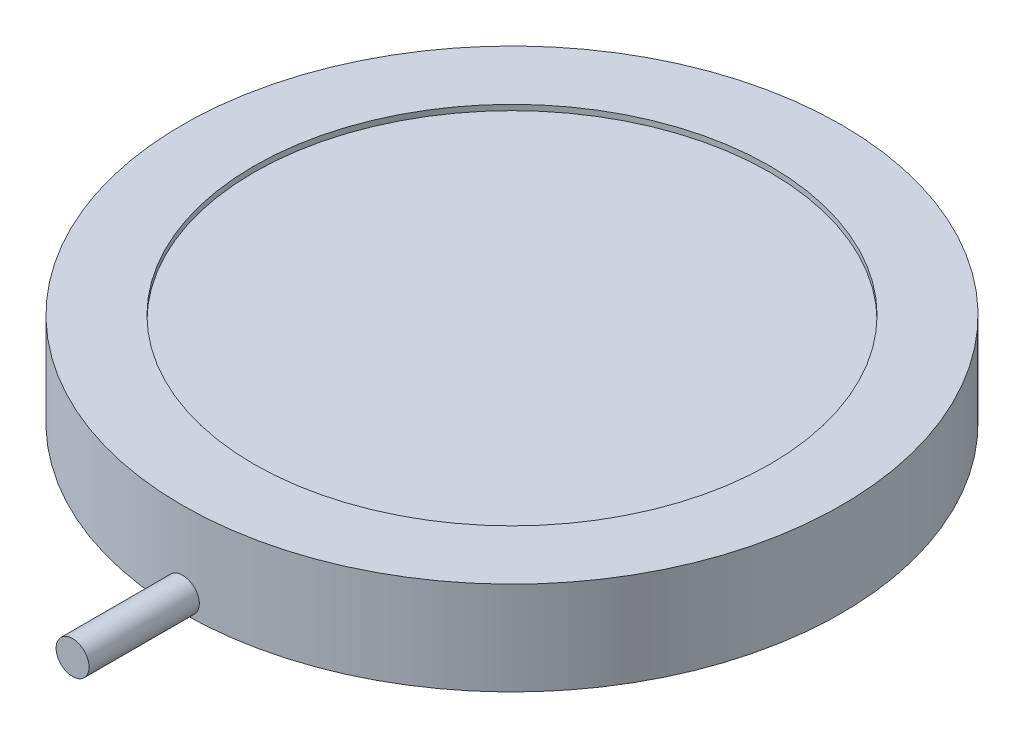
from build123d import *

# Parameters (mm, degrees)
SKETCH_1_R          = 30
EXTRUDE_1_DEPTH     = 8.5
SKETCH_2_R          = 23.5
CUT_EXTRUDE_1_DEPTH = 0.5
SKETCH_3_R          = 1.5
EXTRUDE_2_DEPTH     = 15
SKETCH_4_R          = 1.75
CUT_EXTRUDE_2_DEPTH = 3


with BuildPart() as part:
    # 草图1 → 凸台-拉伸1 (new body)
    with BuildSketch(Plane(origin=(0, 0, 0), x_dir=(1, 0, 0), z_dir=(0, 1, 0))):
        Circle(SKETCH_1_R)
    extrude(amount=EXTRUDE_1_DEPTH)

    # 草图2 → 切除-拉伸1 (cut)
    with BuildSketch(Plane(origin=(0, 8.5, 0), x_dir=(1, 0, 0), z_dir=(0, 1, 0))):
        Circle(SKETCH_2_R)
    extrude(amount=-CUT_EXTRUDE_1_DEPTH, mode=Mode.SUBTRACT)

    # 草图3 → 凸台-拉伸2 (add)
    with BuildSketch(Plane.XY.offset(25)):
        with Locations((0, 1.5)):
            Circle(SKETCH_3_R)
    extrude(amount=EXTRUDE_2_DEPTH)

    # 草图4 → 切除-拉伸2 (cut)
    with BuildSketch(Plane.XZ):
        with Locations((-14, 0)):
            Circle(SKETCH_4_R)
        with Locations((14, 0)):
            Circle(SKETCH_4_R)
    extrude(amount=-CUT_EXTRUDE_2_DEPTH, mode=Mode.SUBTRACT)


solid = part.part
